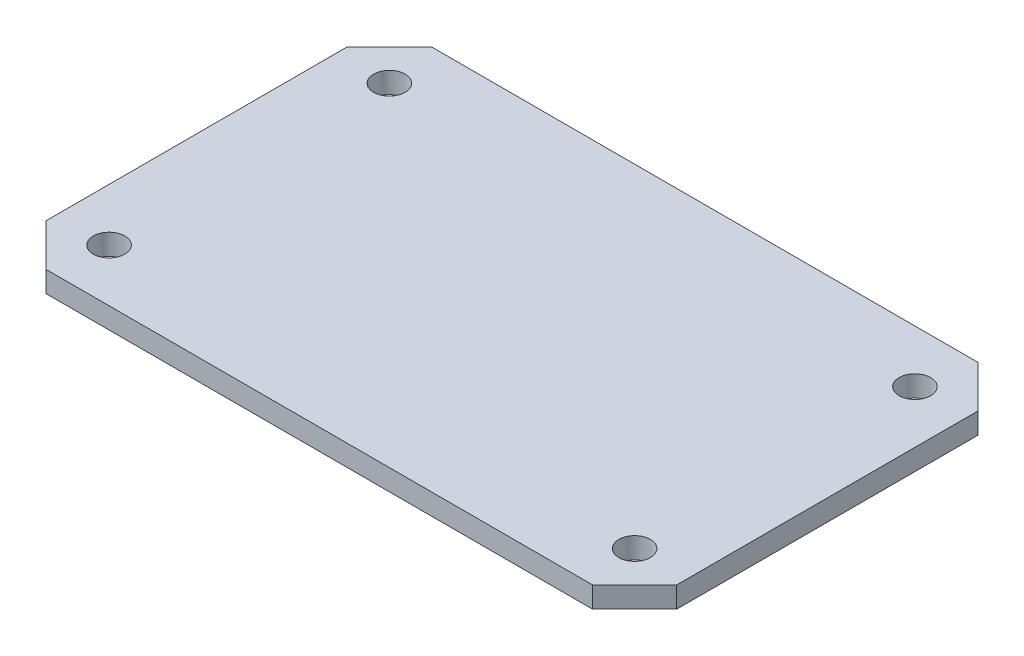
from build123d import *

# Parameters (mm, degrees)
SKETCH1_W            = 90
SKETCH1_H            = 55
BOSS_EXTRUDE1_DEPTH  = 16
SKETCH2_W            = 22
SKETCH2_H            = 1.75
SKETCH2_H_2          = 12.5
CUT_EXTRUDE1_DEPTH   = 4
SKETCH3_W            = 20
SKETCH3_H            = 13
CUT_EXTRUDE2_DEPTH   = 20
CHAMFER1_SIZE        = 6
M4_CLEARANCE_HOLE1_D = 4.5
SKETCH7_W            = 27.5
SKETCH7_H            = 8.5
CUT_EXTRUDE3_DEPTH   = 3
SKETCH8_W            = 16.5
SKETCH8_H            = 8.5
CUT_EXTRUDE4_DEPTH   = 12
SKETCH9_R            = 2.25
CUT_EXTRUDE5_DEPTH   = 17
CHAMFER2_SIZE        = 5
SKETCH10_W           = 4
SKETCH10_H           = 22.5
SKETCH10_R           = 2.25
BOSS_EXTRUDE2_DEPTH  = 3


with BuildPart() as part:
    # Sketch1 → Boss-Extrude1 (new body)
    with BuildSketch(Plane(origin=(0, 0, 0), x_dir=(1, 0, 0), z_dir=(0, 1, 0))):
        Rectangle(SKETCH1_W, SKETCH1_H)
    extrude(amount=BOSS_EXTRUDE1_DEPTH)

    # Sketch2 → Cut-Extrude1 (cut)
    with BuildSketch(Plane.ZY.offset(45)):
        with Locations((0, 15.125)):
            Rectangle(SKETCH2_W, SKETCH2_H)
        Polygon((11, 16), (11, 14.25), (13, 14.25), (11.25, 16), align=None)
        Polygon((-11.25, 16), (-13, 14.25), (-11, 14.25), (-11, 16), align=None)
        Polygon((-17.5, 14.25), (-17.5, 1.75), (-13, 1.75), (-11, 1.75), (-11, 14.25), (-13, 14.25), align=None)
        with Locations((0, 8)):
            Rectangle(SKETCH2_W, SKETCH2_H_2)
        Polygon((11, 14.25), (11, 1.75), (13, 1.75), (17.5, 1.75), (17.5, 14.25), (13, 14.25), align=None)
        with Locations((0, 0.875)):
            Rectangle(SKETCH2_W, SKETCH2_H)
        Polygon((13, 1.75), (11, 1.75), (11, 0), (11.25, 0), align=None)
        Polygon((-11, 1.75), (-13, 1.75), (-11.25, 0), (-11, 0), align=None)
    extrude(amount=-CUT_EXTRUDE1_DEPTH, mode=Mode.SUBTRACT)

    # Sketch3 → Cut-Extrude2 (cut)
    with BuildSketch(Plane.ZY.offset(41)):
        with Locations((0, 8)):
            Rectangle(SKETCH3_W, SKETCH3_H)
    extrude(amount=-CUT_EXTRUDE2_DEPTH, mode=Mode.SUBTRACT)

    # Chamfer1
    chamfer1_edges = [part.edges().sort_by_distance(p)[0] for p in [
        (45, 8, 27.5),
        (-45, 8, 27.5),
        (-45, 8, -27.5),
        (45, 8, -27.5),
    ]]
    chamfer(chamfer1_edges, length=CHAMFER1_SIZE)

    # M4 Clearance Hole1 (through all)
    with Locations(Plane(origin=(0, 16, 0), x_dir=(1, 0, 0), z_dir=(0, 1, 0))):
        with Locations((0, 0), (37.5, 20), (-37.5, -20), (-37.5, 20), (37.5, -20)):
            Hole(M4_CLEARANCE_HOLE1_D / 2)

    # Sketch7 → Cut-Extrude3 (cut)
    with BuildSketch(Plane(origin=(45, 0, 0), x_dir=(0, 0, -1), z_dir=(1, 0, 0))):
        with Locations((0, 8)):
            Rectangle(SKETCH7_W, SKETCH7_H)
    extrude(amount=-CUT_EXTRUDE3_DEPTH, mode=Mode.SUBTRACT)

    # Sketch8 → Cut-Extrude4 (cut)
    with BuildSketch(Plane(origin=(42, 0, 0), x_dir=(0, 0, -1), z_dir=(1, 0, 0))):
        with Locations((0, 8)):
            Rectangle(SKETCH8_W, SKETCH8_H)
    extrude(amount=-CUT_EXTRUDE4_DEPTH, mode=Mode.SUBTRACT)

    # Sketch9 → Cut-Extrude5 (cut, through all)
    with BuildSketch(Plane(origin=(0, 16, 0), x_dir=(1, 0, 0), z_dir=(0, 1, 0))):
        Polygon((30, -12.5), (40, -12.5), (40, 12.5), (30, 12.5), (30, 22.5), (-30, 22.5), (-30, 12.5), (-36, 12.5), (-36, -12.5), (-30, -12.5), (-30, -22.5), (30, -22.5), align=None)
        Circle(SKETCH9_R, mode=Mode.SUBTRACT)
    extrude(amount=-CUT_EXTRUDE5_DEPTH, mode=Mode.SUBTRACT)

    # Chamfer2
    chamfer2_edges = [part.edges().sort_by_distance(p)[0] for p in [
        (30, 8, -12.5),
        (30, 8, 12.5),
        (-30, 8, 12.5),
        (-30, 8, -12.5),
    ]]
    chamfer(chamfer2_edges, length=CHAMFER2_SIZE)


with BuildPart() as body_2:
    # Sketch10 → Boss-Extrude2 (new body)
    with BuildSketch(Plane(origin=(0, 16, 0), x_dir=(1, 0, 0), z_dir=(0, 1, 0))):
        with Locations((-43, 0)):
            Rectangle(SKETCH10_W, SKETCH10_H)
        Polygon((39, -27.5), (45, -21.5), (45, 21.5), (39, 27.5), (-39, 27.5), (-45, 21.5), (-45, 11.25), (-41, 11.25), (-41, -11.25), (-45, -11.25), (-45, -21.5), (-39, -27.5), align=None)
        with Locations((37.5, -20)):
            Circle(SKETCH10_R, mode=Mode.SUBTRACT)
        with Locations((-37.5, -20)):
            Circle(SKETCH10_R, mode=Mode.SUBTRACT)
        with Locations((37.5, 20)):
            Circle(SKETCH10_R, mode=Mode.SUBTRACT)
        with Locations((-37.5, 20)):
            Circle(SKETCH10_R, mode=Mode.SUBTRACT)
        Polygon((-36, -12.5), (-36, 12.5), (-35, 12.5), (-30, 17.5), (-30, 22.5), (30, 22.5), (30, 17.5), (35, 12.5), (40, 12.5), (40, -12.5), (35, -12.5), (30, -17.5), (30, -22.5), (-30, -22.5), (-30, -17.5), (-35, -12.5), align=None, mode=Mode.SUBTRACT)
        Polygon((-36, 12.5), (-35, 12.5), (-30, 17.5), (-30, 22.5), (30, 22.5), (30, 17.5), (35, 12.5), (40, 12.5), (40, -12.5), (35, -12.5), (30, -17.5), (30, -22.5), (-30, -22.5), (-30, -17.5), (-35, -12.5), (-36, -12.5), align=None)
    extrude(amount=BOSS_EXTRUDE2_DEPTH)


solid = body_2.part
